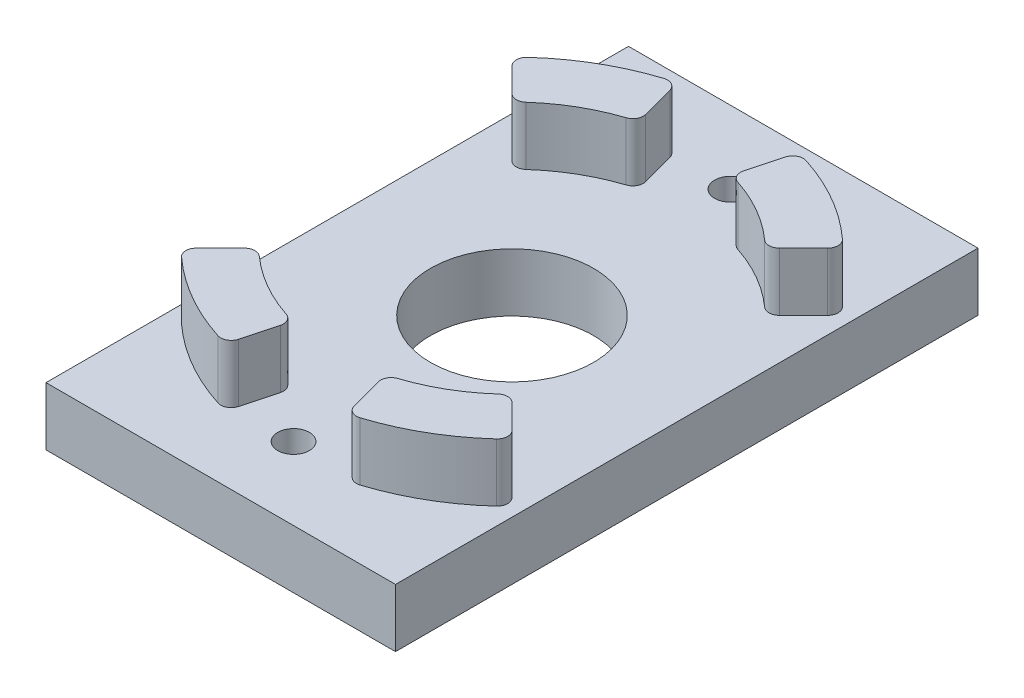
from build123d import *

# Parameters (mm, degrees)
SKETCH1_W                 = 38.1
SKETCH1_H                 = 63.5
BOSS_EXTRUDE1_DEPTH       = 6.35
BOSS_EXTRUDE2_DEPTH       = 6.35
FILLET1_R                 = 1.143
CIRPATTERN1_COUNT         = 6
FILLET1_OF_CIRPATTERN1_R  = 1.143
SKETCH3_R                 = 8.89
CUT_EXTRUDE1_DEPTH        = 7.35
F_8_32_TAPPED_HOLE1_D     = 3.4544
F_8_32_TAPPED_HOLE1_DEPTH = 6.35


with BuildPart() as part:
    # Sketch1 → Boss-Extrude1 (new body)
    with BuildSketch(Plane(origin=(0, 0, 0), x_dir=(1, 0, 0), z_dir=(0, 1, 0))):
        Rectangle(SKETCH1_W, SKETCH1_H)
    extrude(amount=BOSS_EXTRUDE1_DEPTH)

    # Sketch2 → Boss-Extrude2 (add)
    with BuildSketch(Plane(origin=(0, 6.35, 0), x_dir=(1, 0, 0), z_dir=(0, 1, 0))):
        with BuildLine():
            Line((-18.032354291, 18.032354291), (-13.793673402, 13.793673402))
            ThreePointArc((-13.793673402, 13.793673402), (-9.7536, 16.893730757), (-5.048834877, 18.842508279))
            Line((-5.048834877, 18.842508279), (-6.600299761, 24.632654052))
            ThreePointArc((-6.600299761, 24.632654052), (-12.7508, 22.085033437), (-18.032354291, 18.032354291))
        make_face()
    boss_extrude2 = extrude(amount=BOSS_EXTRUDE2_DEPTH)

    # Fillet1
    fillet1_edges = [part.edges().sort_by_distance(p)[0] for p in [
        (-6.600299761, 9.525, -24.632654052),
        (-18.032354291, 9.525, -18.032354291),
        (-13.793673402, 9.525, -13.793673402),
        (-5.048834877, 9.525, -18.842508279),
    ]]
    fillet(fillet1_edges, radius=FILLET1_R)

    # CirPattern1: Boss-Extrude2 ×6 about axis, 2 skipped
    cirpattern1_axis = Axis((0, 12.7, 0), (0, 1, 0))
    add([boss_extrude2.rotate(cirpattern1_axis, i * 360 / CIRPATTERN1_COUNT) for i in range(1, CIRPATTERN1_COUNT) if i not in (1, 4)])

    # Fillet1 of CirPattern1
    fillet1_of_cirpattern1_edges = [part.edges().sort_by_distance(p)[0] for p in [
        (-18.032354291, 9.525, 18.032354291),
        (-6.600299761, 9.525, 24.632654052),
        (-5.048834877, 9.525, 18.842508279),
        (-13.793673402, 9.525, 13.793673402),
        (6.600299761, 9.525, 24.632654052),
        (18.032354291, 9.525, 18.032354291),
        (13.793673402, 9.525, 13.793673402),
        (5.048834877, 9.525, 18.842508279),
        (18.032354291, 9.525, -18.032354291),
        (6.600299761, 9.525, -24.632654052),
        (5.048834877, 9.525, -18.842508279),
        (13.793673402, 9.525, -13.793673402),
    ]]
    fillet(fillet1_of_cirpattern1_edges, radius=FILLET1_OF_CIRPATTERN1_R)

    # Sketch3 → Cut-Extrude1 (cut, through all)
    with BuildSketch(Plane(origin=(0, 6.35, 0), x_dir=(1, 0, 0), z_dir=(0, 1, 0))):
        Circle(SKETCH3_R)
    extrude(amount=-CUT_EXTRUDE1_DEPTH, mode=Mode.SUBTRACT)

    # #8-32 Tapped Hole1
    with Locations(Plane(origin=(0, 6.35, 0), x_dir=(1, 0, 0), z_dir=(0, 1, 0))):
        with Locations((0, -23.8125), (0, 23.8125)):
            Hole(F_8_32_TAPPED_HOLE1_D / 2, depth=F_8_32_TAPPED_HOLE1_DEPTH)


solid = part.part
